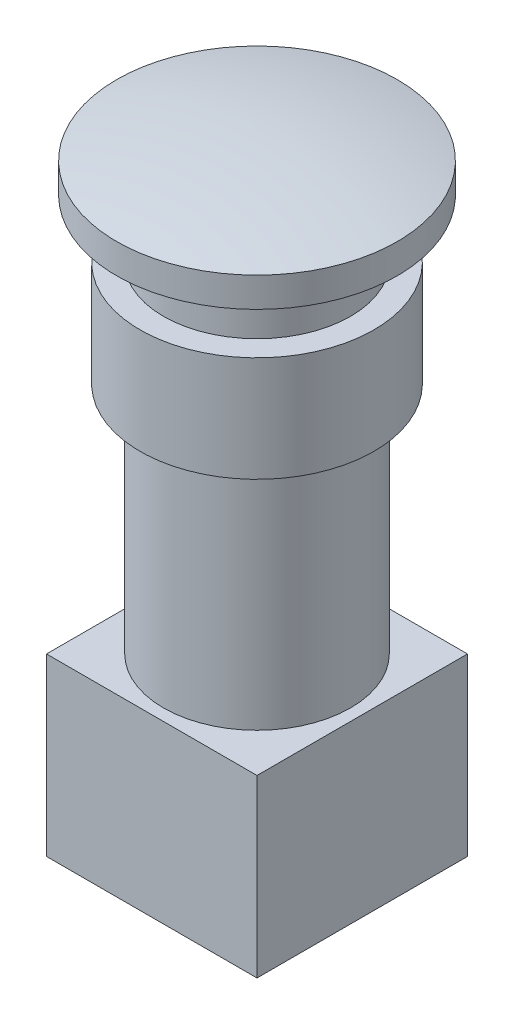
from build123d import *

# Parameters (mm, degrees)
ESQUISSE2_W      = 18
ESQUISSE2_H      = 18
EXTRUSION1_DEPTH = 15


with BuildPart() as part:
    # Esquisse1 → Révolution1 (revolve)
    with BuildSketch(Plane.XY):
        with BuildLine():
            Line((-12, 36.538644398), (-12, 34))
            Line((-12, 34), (-8, 34))
            Line((-8, 34), (-8, 29))
            Line((-8, 29), (-10, 29))
            Line((-10, 29), (-10, 20))
            Line((-10, 20), (-8, 20))
            Line((-8, 20), (-8, 0))
            Line((-8, 0), (0, 0))
            Line((0, 0), (0, 38))
            ThreePointArc((0, 38), (-6.044327096, 37.633316532), (-12, 36.538644398))
        make_face()
    revolve(axis=Axis((0, 0, 0), (0, 1, 0)))

    # Esquisse2 → Extrusion1 (add)
    with BuildSketch(Plane.XZ):
        Rectangle(ESQUISSE2_W, ESQUISSE2_H)
    extrude(amount=EXTRUSION1_DEPTH)


solid = part.part
